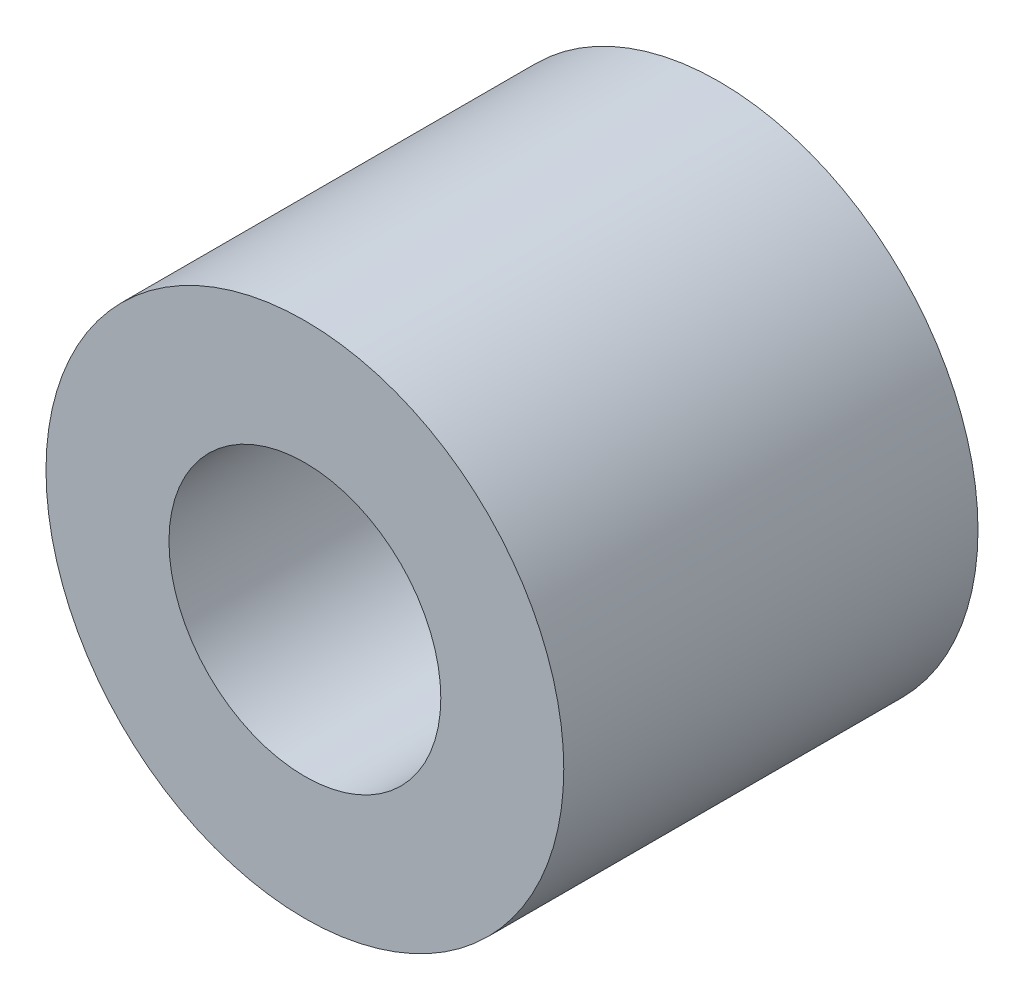
from build123d import *

# Parameters (mm, degrees)
SKETCH_1_R      = 4
SKETCH_1_R_2    = 2.1
EXTRUDE_1_DEPTH = 6.4


with BuildPart() as part:
    # ｽｹｯﾁ1 → ﾎﾞｽ - 押し出し1 (new body)
    with BuildSketch(Plane.XY):
        Circle(SKETCH_1_R)
        Circle(SKETCH_1_R_2, mode=Mode.SUBTRACT)
    extrude(amount=EXTRUDE_1_DEPTH)


solid = part.part
